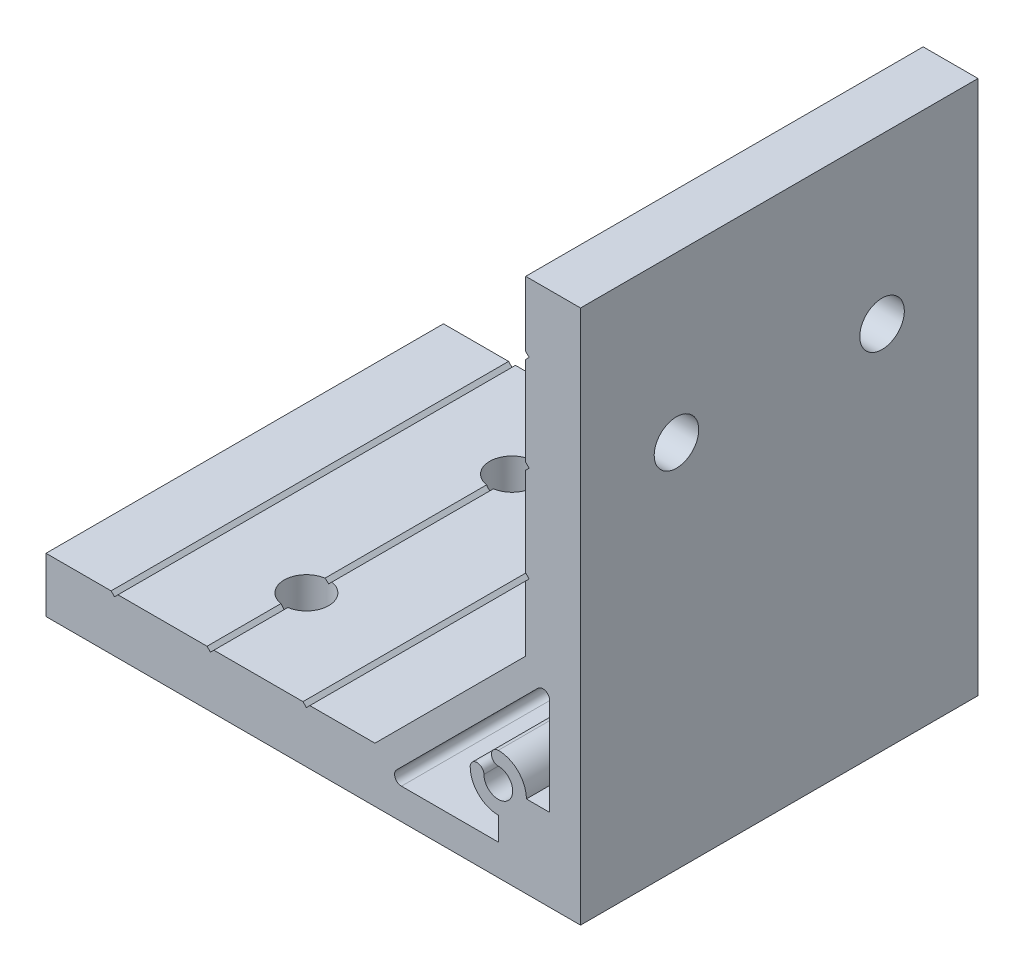
from build123d import *

# Parameters (mm, degrees)
EXTRUDE_1_DEPTH     = 29
SKETCH_2_R          = 3.25
CUT_EXTRUDE_1_DEPTH = 9
SKETCH_3_R          = 3.25
CUT_EXTRUDE_2_DEPTH = 9


with BuildPart() as part:
    # Эскиз1 → Бобышка-Вытянуть1 (new body, symmetric)
    with BuildSketch(Plane.XY):
        Polygon((-78, 0), (0, 0), (0, 78), (-8, 78), (-8, 68.5), (-7.5, 68), (-8, 67.5), (-8, 54.5), (-7.5, 54), (-8, 53.5), (-8, 40.5), (-7.5, 40), (-8, 39.5), (-8, 30), (-30, 8), (-39.5, 8), (-40, 7.5), (-40.5, 8), (-53.5, 8), (-54, 7.5), (-54.5, 8), (-67.5, 8), (-68, 7.5), (-68.5, 8), (-78, 8), align=None)
        with BuildLine():
            Line((-4.5, 12), (-4.5, 26.136038969))
            ThreePointArc((-4.5, 26.136038969), (-5.117316568, 27.059918502), (-6.207106781, 26.843145751))
            Line((-6.207106781, 26.843145751), (-26.843145751, 6.207106781))
            ThreePointArc((-26.843145751, 6.207106781), (-27.059918502, 5.117316568), (-26.136038969, 4.5))
            Line((-26.136038969, 4.5), (-12, 4.5))
            Line((-12, 4.5), (-12, 7.9))
            ThreePointArc((-12, 7.9), (-14.899137803, 9.100862197), (-16.1, 12))
            ThreePointArc((-16.1, 12), (-15.1, 13), (-14.1, 12))
            ThreePointArc((-14.1, 12), (-10.51507576, 10.51507576), (-12, 14.1))
            ThreePointArc((-12, 14.1), (-13, 15.1), (-12, 16.1))
            ThreePointArc((-12, 16.1), (-9.100862197, 14.899137803), (-7.9, 12))
            Line((-7.9, 12), (-4.5, 12))
        make_face(mode=Mode.SUBTRACT)
    extrude(amount=EXTRUDE_1_DEPTH, both=True)

    # Эскиз2 → Вырез-Вытянуть1 (cut, through all)
    with BuildSketch(Plane.ZY.offset(8)):
        with Locations(Location((-15, 54, 0), (0, 0, 270))):  # turned: the seam where the file's is
            Circle(SKETCH_2_R)
        with Locations(Location((15, 54, 0), (0, 0, 270))):  # turned: the seam where the file's is
            Circle(SKETCH_2_R)
    extrude(amount=-CUT_EXTRUDE_1_DEPTH, mode=Mode.SUBTRACT)

    # Эскиз3 → Вырез-Вытянуть2 (cut, through all)
    with BuildSketch(Plane(origin=(0, 8, 0), x_dir=(1, 0, 0), z_dir=(0, 1, 0))):
        with Locations(Location((-54, -15, 0), (0, 0, 180))):  # turned: the seam where the file's is
            Circle(SKETCH_3_R)
        with Locations(Location((-54, 15, 0), (0, 0, 180))):  # turned: the seam where the file's is
            Circle(SKETCH_3_R)
    extrude(amount=-CUT_EXTRUDE_2_DEPTH, mode=Mode.SUBTRACT)


solid = part.part
